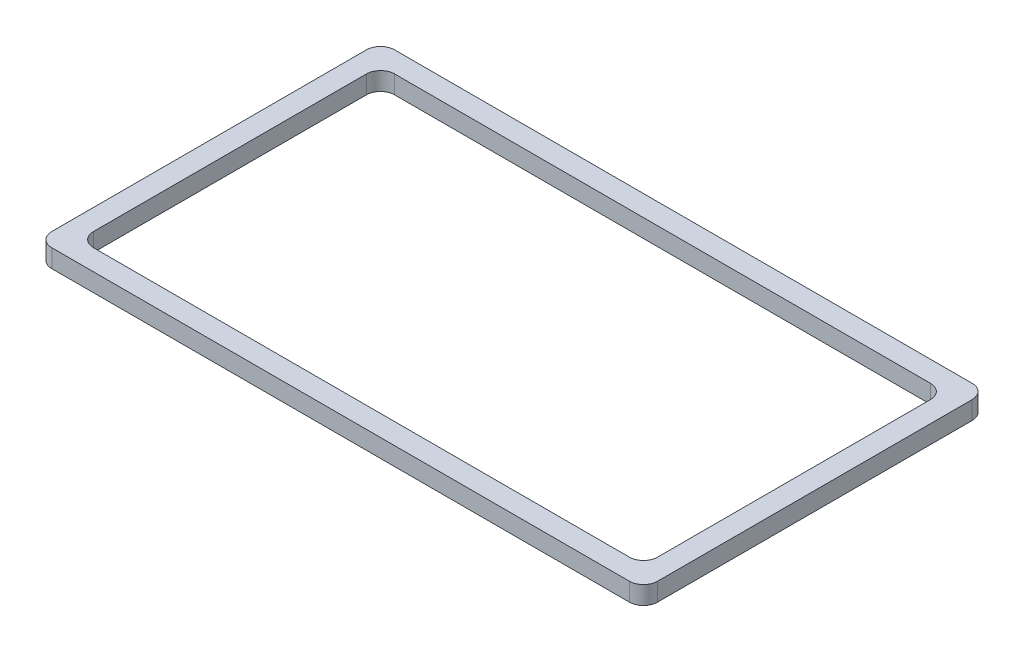
from build123d import *

# Parameters (mm, degrees)
SKETCH1_W           = 66.8
SKETCH1_H           = 37.8
SKETCH1_W_2         = 62.2
SKETCH1_H_2         = 33.2
BOSS_EXTRUDE1_DEPTH = 2
FILLET1_R           = 1.55


with BuildPart() as part:
    # Sketch1 → Boss-Extrude1 (new body)
    with BuildSketch(Plane(origin=(0, 0, 0), x_dir=(1, 0, 0), z_dir=(0, 1, 0))):
        with Locations((33.4, 18.9)):
            Rectangle(SKETCH1_W, SKETCH1_H)
        with Locations((33.4, 18.9)):
            Rectangle(SKETCH1_W_2, SKETCH1_H_2, mode=Mode.SUBTRACT)
    extrude(amount=BOSS_EXTRUDE1_DEPTH)

    # Fillet1
    fillet1_edges = [part.edges().sort_by_distance(p)[0] for p in [
        (2.3, 1, -35.5),
        (2.3, 1, -2.3),
        (64.5, 1, -2.3),
        (64.5, 1, -35.5),
        (0, 1, -37.8),
        (66.8, 1, -37.8),
        (66.8, 1, 0),
        (0, 1, 0),
    ]]
    fillet(fillet1_edges, radius=FILLET1_R)


solid = part.part
